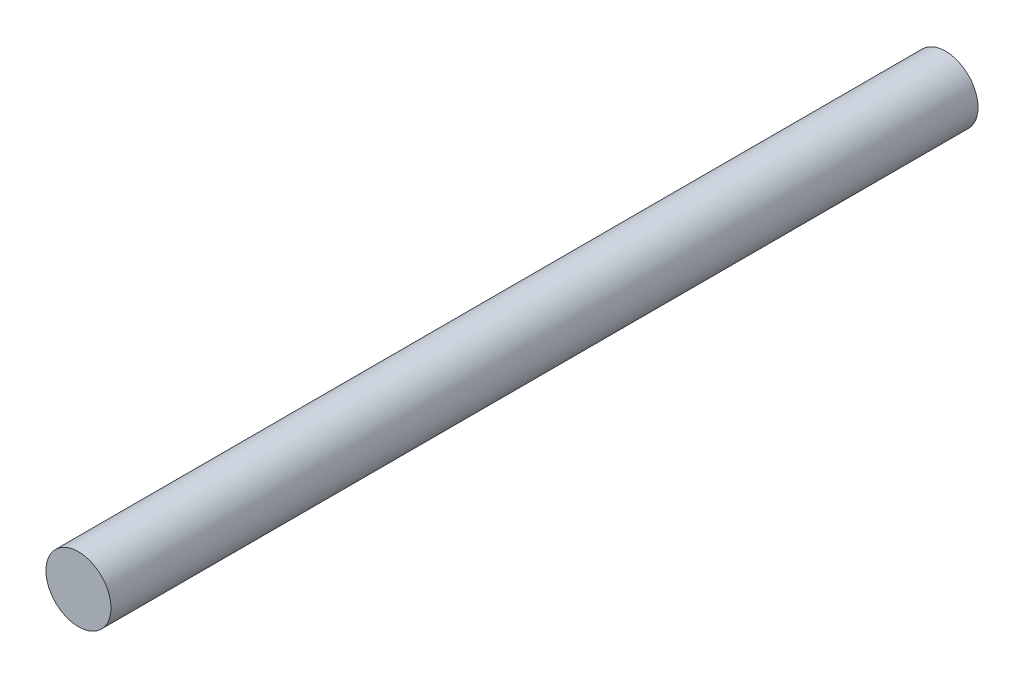
from build123d import *

# Parameters (mm, degrees)
SKETCH1_R           = 0.75
BOSS_EXTRUDE1_DEPTH = 20


with BuildPart() as part:
    # Sketch1 → Boss-Extrude1 (new body)
    with BuildSketch(Plane.XY):
        Circle(SKETCH1_R)
    extrude(amount=BOSS_EXTRUDE1_DEPTH)


solid = part.part
